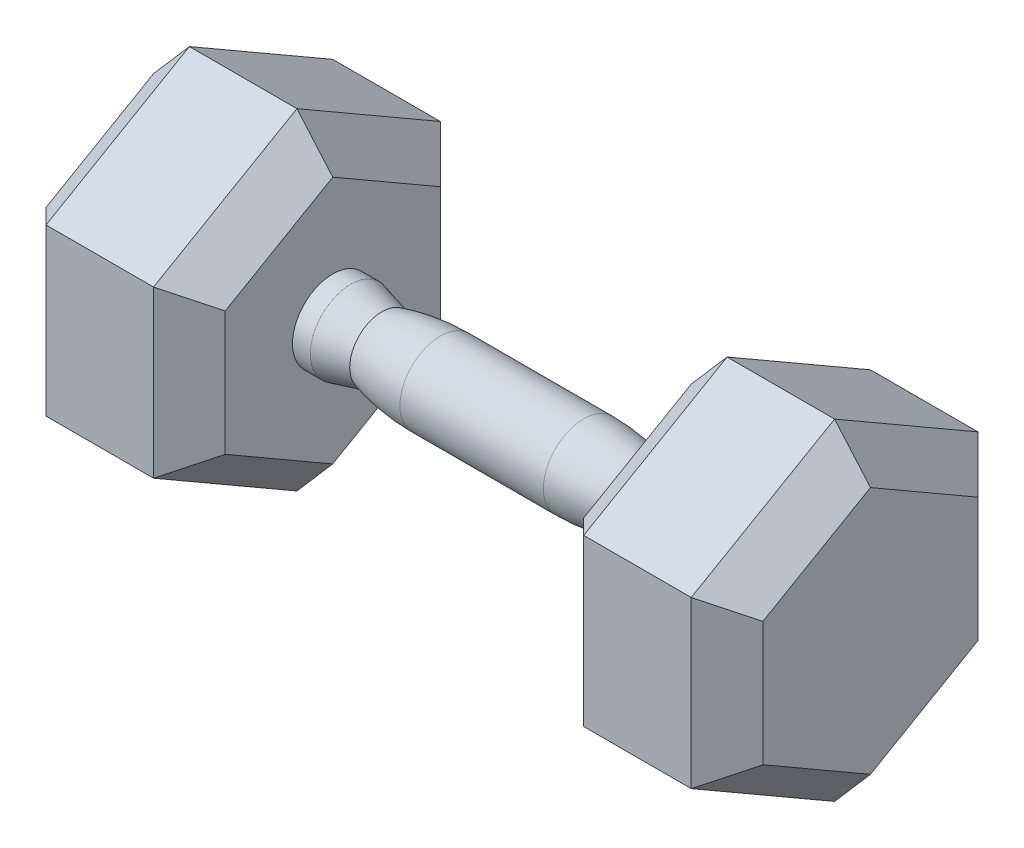
from build123d import *

# Parameters (mm, degrees)
BOSS_EXTRUDE1_DEPTH = 63.5
CHAMFER1_SIZE       = 12.7
CHAMFER2_SIZE       = 12.7


with BuildPart() as part:
    # Sketch1 → Boss-Extrude1 (new body)
    with BuildSketch(Plane.YZ):
        Polygon((58.65878735, 0), (29.329393675, 50.8), (-29.329393675, 50.8), (-58.65878735, 0), (-29.329393675, -50.8), (29.329393675, -50.8), align=None)
    extrude(amount=BOSS_EXTRUDE1_DEPTH)

    # Chamfer1
    chamfer1_edges = [part.edges().sort_by_distance(p)[0] for p in [
        (63.5, 0, 50.8),
        (63.5, -43.994090512, 25.4),
        (63.5, -43.994090512, -25.4),
        (63.5, 0, -50.8),
        (63.5, 43.994090512, -25.4),
        (63.5, 43.994090512, 25.4),
    ]]
    chamfer(chamfer1_edges, length=CHAMFER1_SIZE)

    # Chamfer2
    chamfer2_edges = [part.edges().sort_by_distance(p)[0] for p in [
        (0, 0, -50.8),
        (0, -43.994090512, -25.4),
        (0, -43.994090512, 25.4),
        (0, 0, 50.8),
        (0, 43.994090512, 25.4),
        (0, 43.994090512, -25.4),
    ]]
    chamfer(chamfer2_edges, length=CHAMFER2_SIZE)

    # Sketch2 → Revolve1 (revolve)
    with BuildSketch(Plane(origin=(0, 0, 0), x_dir=(-1, 0, 0), z_dir=(0, 1, 0))):
        with BuildLine():
            Line((0, 0), (0, 14.2875))
            Line((0, 14.2875), (6.35, 14.2875))
            Line((6.35, 14.2875), (17.42833597, 11.43))
            ThreePointArc((17.42833597, 11.43), (27.66588528, 13.569744601), (38.1, 14.2875))
            Line((38.1, 14.2875), (63.5, 14.2875))
            Line((63.5, 14.2875), (63.5, 0))
            Line((63.5, 0), (0, 0))
        make_face()
    revolve(axis=Axis((-63.5, 0, 0), (1, 0, 0)))

    # Mirror1: part across plane


with BuildPart() as part_1:
    add(part.part)
    add(part.part.mirror(Plane(origin=(-63.5, 0, 14.2875), x_dir=(0, 0, 1), z_dir=(-1, 0, 0))))


solid = part_1.part
